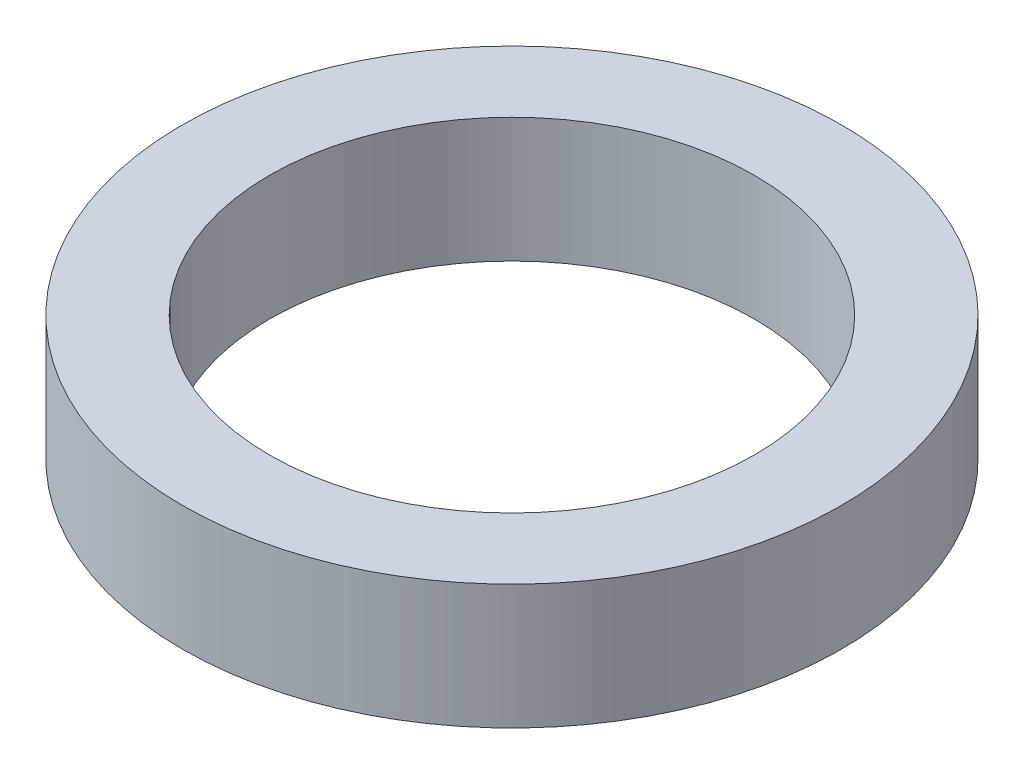
from build123d import *

# Parameters (mm, degrees)
SKETCH1_R           = 317.5
BOSS_EXTRUDE1_DEPTH = 120
SKETCH2_R           = 233.5
CUT_EXTRUDE1_DEPTH  = 121


with BuildPart() as part:
    # Sketch1 → Boss-Extrude1 (new body)
    with BuildSketch(Plane(origin=(0, 0, 0), x_dir=(1, 0, 0), z_dir=(0, 1, 0))):
        Circle(SKETCH1_R)
    extrude(amount=BOSS_EXTRUDE1_DEPTH)

    # Sketch2 → Cut-Extrude1 (cut, through all)
    with BuildSketch(Plane(origin=(0, 120, 0), x_dir=(1, 0, 0), z_dir=(0, 1, 0))):
        Circle(SKETCH2_R)
    extrude(amount=-CUT_EXTRUDE1_DEPTH, mode=Mode.SUBTRACT)


solid = part.part
